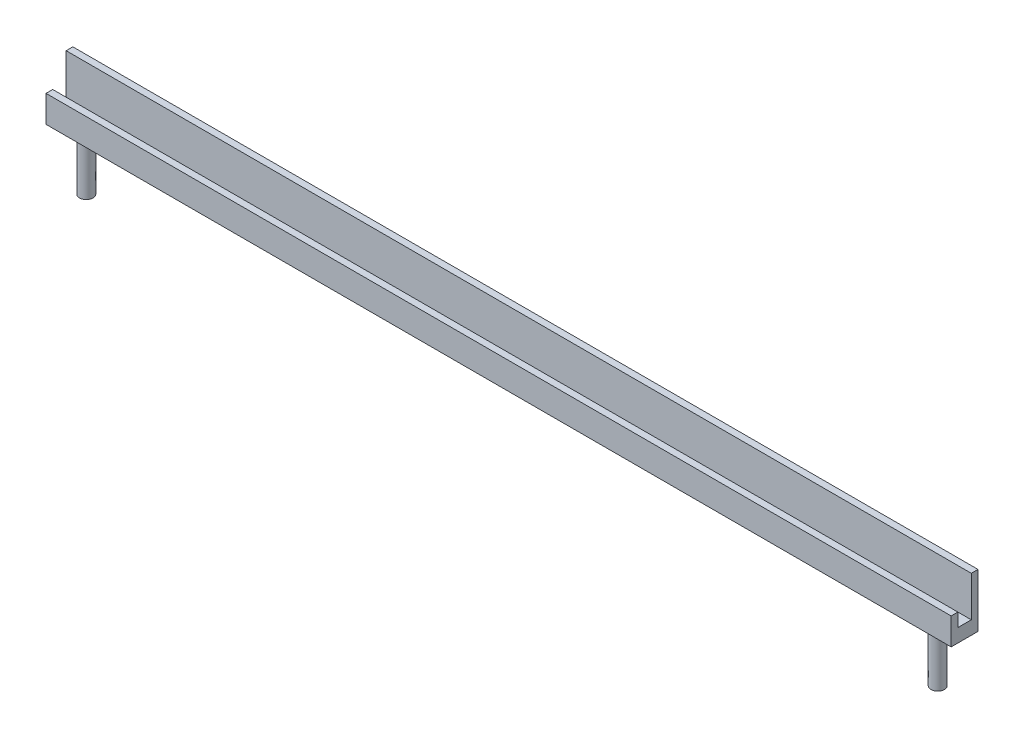
from build123d import *

# Parameters (mm, degrees)
SKETCH1_W           = 337
SKETCH1_H           = 10
BOSS_EXTRUDE1_DEPTH = 5
SKETCH2_W           = 337
SKETCH2_H           = 2.5
BOSS_EXTRUDE2_DEPTH = 5
SKETCH3_W           = 337
SKETCH3_H           = 2.5
BOSS_EXTRUDE3_DEPTH = 15
SKETCH4_R           = 2.5
BOSS_EXTRUDE4_DEPTH = 20


with BuildPart() as part:
    # Sketch1 → Boss-Extrude1 (new body)
    with BuildSketch(Plane(origin=(0, 0, 0), x_dir=(1, 0, 0), z_dir=(0, 1, 0))):
        Rectangle(SKETCH1_W, SKETCH1_H)
    extrude(amount=BOSS_EXTRUDE1_DEPTH)

    # Sketch2 → Boss-Extrude2 (add)
    with BuildSketch(Plane(origin=(0, 5, 0), x_dir=(1, 0, 0), z_dir=(0, 1, 0))):
        with Locations((0, -3.75)):
            Rectangle(SKETCH2_W, SKETCH2_H)
    extrude(amount=BOSS_EXTRUDE2_DEPTH)

    # Sketch3 → Boss-Extrude3 (add)
    with BuildSketch(Plane(origin=(0, 5, 0), x_dir=(1, 0, 0), z_dir=(0, 1, 0))):
        with Locations((0, 3.75)):
            Rectangle(SKETCH3_W, SKETCH3_H)
    extrude(amount=BOSS_EXTRUDE3_DEPTH)

    # Sketch4 → Boss-Extrude4 (add)
    with BuildSketch(Plane.XZ):
        with Locations((-158.5, 0)):
            Circle(SKETCH4_R)
        with Locations((158.5, 0)):
            Circle(SKETCH4_R)
    extrude(amount=BOSS_EXTRUDE4_DEPTH)


solid = part.part
